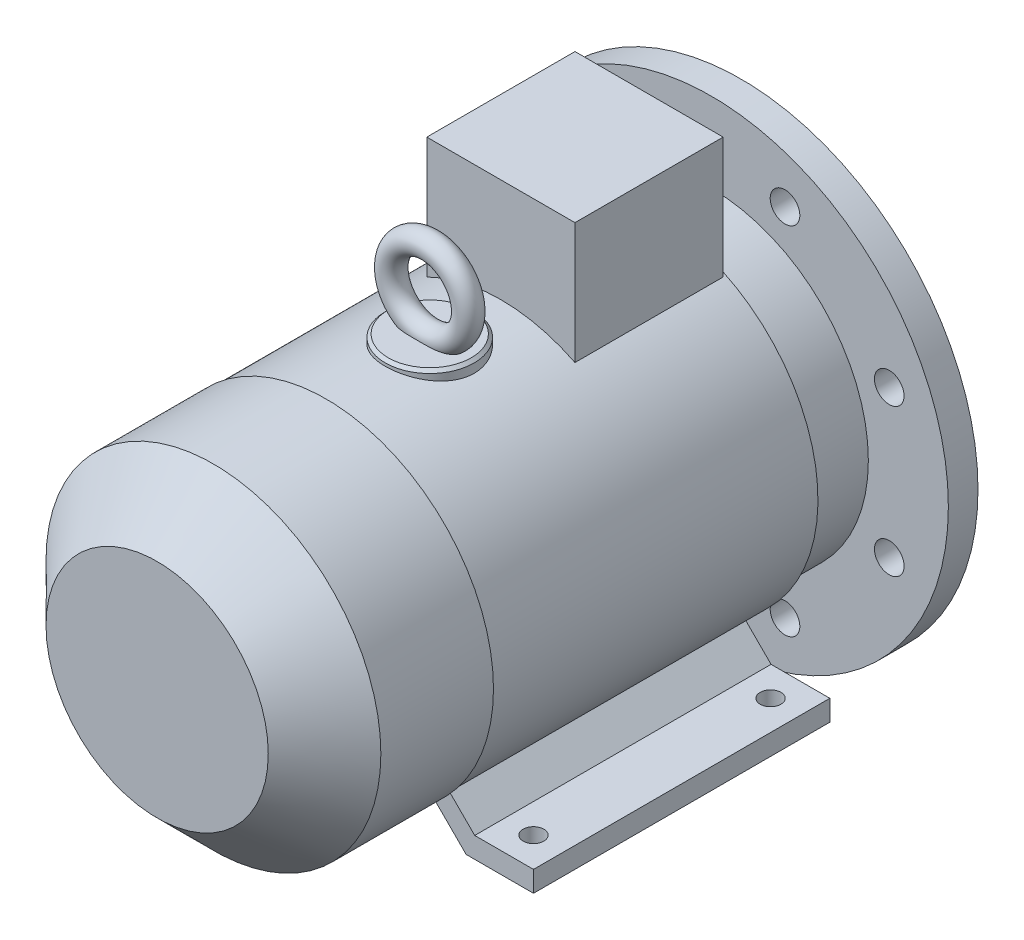
from build123d import *

# Parameters (mm, degrees)
SKETCH_1_R           = 7
EXTRUDE_1_DEPTH      = 30
SKETCH_2_W           = 5
SKETCH_2_H           = 5
EXTRUDE_2_DEPTH      = 0.1
EXTRUDE_2_DEPTH_BACK = 20
SKETCH_3_R           = 9
EXTRUDE_3_DEPTH      = 4
SKETCH_4_R           = 80
SKETCH_4_R_2         = 52
EXTRUDE_4_DEPTH      = 10
SKETCH_5_R           = 53
EXTRUDE_5_DEPTH      = 26
SKETCH_7_R           = 55
SKETCH_7_R_2         = 52
EXTRUDE_6_DEPTH      = 7.5
CHAMFER_1_SIZE       = 0.5
SKETCH_8_R           = 5
CUT_EXTRUDE_1_DEPTH  = 31
SKETCH_10_R          = 56
EXTRUDE_7_DEPTH      = 110
SKETCH_11_R          = 56.5
EXTRUDE_8_DEPTH      = 57
CHAMFER_2_SIZE       = 19
EXTRUDE_9_DEPTH      = 100
CUT_EXTRUDE_2_REACH  = 145
SKETCH_13_R          = 3.5
SKETCH_14_W          = 50
SKETCH_14_H          = 50
EXTRUDE_10_DEPTH     = 91
SKETCH_15_R          = 15
EXTRUDE_11_DEPTH     = 58
CHAMFER_3_SIZE       = 1
SKETCH_17_R          = 4
SKETCH_18_R          = 7
EXTRUDE_12_DEPTH     = 4
EXTRUDE_13_DEPTH     = 7
SKETCH_20_R          = 4
CUT_EXTRUDE_3_DEPTH  = 7


with BuildPart() as part:
    # Эскиз1 → Вытянуть1 (new body)
    with BuildSketch(Plane.XY):
        Circle(SKETCH_1_R)
    extrude(amount=EXTRUDE_1_DEPTH)

    # Эскиз2 → Вытянуть2 (add, two sides)
    with BuildSketch(Plane(origin=(0, 0, 0), x_dir=(-1, 0, 0), z_dir=(0, 0, -1))) as extrude_2_sk:
        with Locations((0, 6.5)):
            Rectangle(SKETCH_2_W, SKETCH_2_H)
    extrude(amount=EXTRUDE_2_DEPTH)
    extrude(extrude_2_sk.sketch, amount=-EXTRUDE_2_DEPTH_BACK)

    # Эскиз3 → Вытянуть3 (add)
    with BuildSketch(Plane.XY.offset(30)):
        Circle(SKETCH_3_R)
    extrude(amount=EXTRUDE_3_DEPTH)



with BuildPart() as body_2:
    # Эскиз4 → Вытянуть4 (new body)
    with BuildSketch(Plane(origin=(0, 0, 30), x_dir=(-1, 0, 0), z_dir=(0, 0, -1))):
        Circle(SKETCH_4_R)
        Circle(SKETCH_4_R_2, mode=Mode.SUBTRACT)
    extrude(amount=-EXTRUDE_4_DEPTH)


with BuildPart() as part_1:
    add(part.part)

    add(body_2.part)  # Вытянуть5 merges body 2
    # Эскиз5 → Вытянуть5 (add)
    with BuildSketch(Plane.XY.offset(34)):
        with Locations(Location((0, 0, 0), (0, 0, 180))):  # turned: the seam where the file's is
            Circle(SKETCH_5_R)
    extrude(amount=EXTRUDE_5_DEPTH)

    # Эскиз7 → Вытянуть6 (add)
    with BuildSketch(Plane(origin=(0, 0, 34), x_dir=(-1, 0, 0), z_dir=(0, 0, -1))):
        Circle(SKETCH_7_R)
        Circle(SKETCH_7_R_2, mode=Mode.SUBTRACT)
    extrude(amount=EXTRUDE_6_DEPTH)

    # Фаска1
    chamfer_1_edges = [part_1.edges().sort_by_distance(p)[0] for p in [
        (55, 0, 26.5),
        (-3.968626967, -5.766281297, 0),
    ]]
    chamfer(chamfer_1_edges, length=CHAMFER_1_SIZE)

    # Эскиз8 → Вырез-Вытянуть1 (cut, through all)
    with BuildSketch(Plane(origin=(0, 0, 30), x_dir=(-1, 0, 0), z_dir=(0, 0, -1))):
        with Locations((-24.874423104, 60.052169613)):
            Circle(SKETCH_8_R)
        with Locations((24.874423104, 60.052169613)):
            Circle(SKETCH_8_R)
        with Locations((60.052169613, 24.874423104)):
            Circle(SKETCH_8_R)
        with Locations((60.052169613, -24.874423104)):
            Circle(SKETCH_8_R)
        with Locations((24.874423104, -60.052169613)):
            Circle(SKETCH_8_R)
        with Locations((-24.874423104, -60.052169613)):
            Circle(SKETCH_8_R)
        with Locations((-60.052169613, -24.874423104)):
            Circle(SKETCH_8_R)
        with Locations((-60.052169613, 24.874423104)):
            Circle(SKETCH_8_R)
    extrude(amount=-CUT_EXTRUDE_1_DEPTH, mode=Mode.SUBTRACT)

    # Эскиз10 → Вытянуть7 (add)
    with BuildSketch(Plane.XY.offset(60)):
        Circle(SKETCH_10_R)
    extrude(amount=EXTRUDE_7_DEPTH)

    # Эскиз11 → Вытянуть8 (add)
    with BuildSketch(Plane.XY.offset(170)):
        Circle(SKETCH_11_R)
    extrude(amount=EXTRUDE_8_DEPTH)

    # Фаска2
    chamfer_2_edges = [part_1.edges().sort_by_distance(p)[0] for p in [
        (-56.5, 0, 227),
    ]]
    chamfer(chamfer_2_edges, length=CHAMFER_2_SIZE)

    # Эскиз12 → Вытянуть9 (add)
    with BuildSketch(Plane(origin=(0, 0, 60), x_dir=(-1, 0, 0), z_dir=(0, 0, -1))):
        Polygon((-60, -56), (-40.169137476, -56), (-29.800227926, -45.631090449), (-23.461287878, -49.191645338), (-37.26964254, -63), (-60, -63), align=None)
        Polygon((41.115933076, -56), (60, -56), (60, -63), (38.21643814, -63), (24.472073526, -49.255635387), (30.369884473, -45.253951397), align=None)
    extrude(amount=-EXTRUDE_9_DEPTH)

    # Эскиз13 → Вырез-Вытянуть2 (cut, up to next)
    with BuildSketch(Plane.XZ.offset(63), mode=Mode.PRIVATE) as cut_extrude_2_sk1:
        with Locations((-50, 70)):
            Circle(SKETCH_13_R)
    cut_extrude_2_tool1 = extrude(cut_extrude_2_sk1.sketch, amount=-CUT_EXTRUDE_2_REACH, mode=Mode.PRIVATE) & part_1.part
    add(cut_extrude_2_tool1.solids().sort_by_distance((-50, -63, 70))[0], mode=Mode.SUBTRACT)
    # Эскиз13 → Вырез-Вытянуть2 (cut, up to next)
    with BuildSketch(Plane.XZ.offset(63), mode=Mode.PRIVATE) as cut_extrude_2_sk2:
        with Locations((50, 70)):
            Circle(SKETCH_13_R)
    cut_extrude_2_tool2 = extrude(cut_extrude_2_sk2.sketch, amount=-CUT_EXTRUDE_2_REACH, mode=Mode.PRIVATE) & part_1.part
    add(cut_extrude_2_tool2.solids().sort_by_distance((50, -63, 70))[0], mode=Mode.SUBTRACT)
    # Эскиз13 → Вырез-Вытянуть2 (cut, up to next)
    with BuildSketch(Plane.XZ.offset(63), mode=Mode.PRIVATE) as cut_extrude_2_sk3:
        with Locations((-50, 150)):
            Circle(SKETCH_13_R)
    cut_extrude_2_tool3 = extrude(cut_extrude_2_sk3.sketch, amount=-CUT_EXTRUDE_2_REACH, mode=Mode.PRIVATE) & part_1.part
    add(cut_extrude_2_tool3.solids().sort_by_distance((-50, -63, 150))[0], mode=Mode.SUBTRACT)
    # Эскиз13 → Вырез-Вытянуть2 (cut, up to next)
    with BuildSketch(Plane.XZ.offset(63), mode=Mode.PRIVATE) as cut_extrude_2_sk4:
        with Locations((50, 150)):
            Circle(SKETCH_13_R)
    cut_extrude_2_tool4 = extrude(cut_extrude_2_sk4.sketch, amount=-CUT_EXTRUDE_2_REACH, mode=Mode.PRIVATE) & part_1.part
    add(cut_extrude_2_tool4.solids().sort_by_distance((50, -63, 150))[0], mode=Mode.SUBTRACT)

    # Эскиз14 → Вытянуть10 (add)
    with BuildSketch(Plane(origin=(0, 0, 0), x_dir=(1, 0, 0), z_dir=(0, 1, 0))):
        with Locations((0, -86)):
            Rectangle(SKETCH_14_W, SKETCH_14_H)
    extrude(amount=EXTRUDE_10_DEPTH)

    # Эскиз15 → Вытянуть11 (add)
    with BuildSketch(Plane(origin=(0, 0, 0), x_dir=(1, 0, 0), z_dir=(0, 1, 0))):
        with Locations(Location((0, -135, 0), (0, 0, 90))):  # turned: the seam where the file's is
            Circle(SKETCH_15_R)
    extrude(amount=EXTRUDE_11_DEPTH)

    # Фаска3
    chamfer_3_edges = [part_1.edges().sort_by_distance(p)[0] for p in [
        (0, 58, 150),
    ]]
    chamfer(chamfer_3_edges, length=CHAMFER_3_SIZE)

    # По траектории1: sweep along a path in Эскиз16
    with BuildLine(Plane.XY.offset(135)) as sweep_1_path:
        CenterArc((0, 71), 13, 0, 360)
    # Эскиз17 → По траектории1 (sweep)
    with BuildSketch(Plane(origin=(0, 0, 0), x_dir=(0, 0, -1), z_dir=(1, 0, 0))):
        with Locations((-135, 84)):
            Circle(SKETCH_17_R)
    sweep(path=sweep_1_path.line)

    # Эскиз18 → Вытянуть12 (add)
    with BuildSketch(Plane.ZY.offset(25)):
        with Locations(Location((86, 69, 0), (0, 0, 180))):  # turned: the seam where the file's is
            Circle(SKETCH_18_R)
    extrude(amount=EXTRUDE_12_DEPTH)

    # Эскиз19 → Вытянуть13 (add)
    with BuildSketch(Plane.ZY.offset(29)):
        Polygon((86, 78.814954576), (77.5, 73.907477288), (77.5, 64.092522712), (86, 59.185045424), (94.5, 64.092522712), (94.5, 73.907477288), align=None)
    extrude(amount=EXTRUDE_13_DEPTH)

    # Эскиз20 → Вырез-Вытянуть3 (cut)
    with BuildSketch(Plane.ZY.offset(36)):
        with Locations((86, 69)):
            Circle(SKETCH_20_R)
    extrude(amount=-CUT_EXTRUDE_3_DEPTH, mode=Mode.SUBTRACT)


solid = part_1.part
